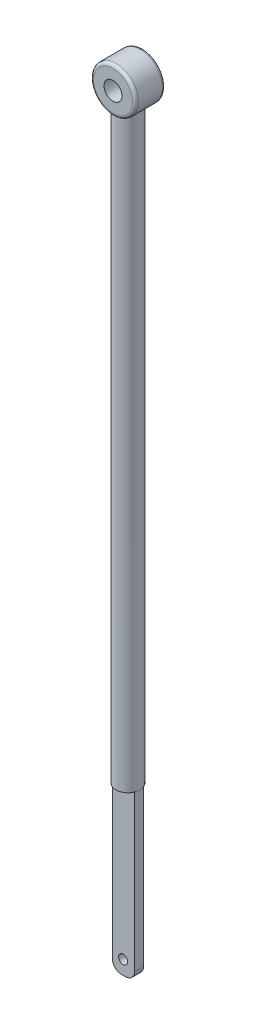
from build123d import *

# Parameters (mm, degrees)
SKETCH_1_R          = 0.75
SKETCH_1_R_2        = 0.3
EXTRUDE_1_DEPTH     = 1
FILLET_1_R          = 0.1
EXTRUDE_2_DEPTH     = 40
SKETCH_3_R          = 2.953544
CUT_EXTRUDE_1_DEPTH = 20
SKETCH_4_W          = 0.74162
SKETCH_4_H          = 0.3
EXTRUDE_3_DEPTH     = 5.5
SKETCH_6_R          = 0.15
CUT_EXTRUDE_2_DEPTH = 5.5
FILLET_2_R          = 0.3


with BuildPart() as part:
    # 草图1 → 凸台-拉伸1 (new body)
    with BuildSketch(Plane.XY):
        with Locations((0.75, 0)):
            Circle(SKETCH_1_R)
        with Locations((0.75, 0)):
            Circle(SKETCH_1_R_2, mode=Mode.SUBTRACT)
    extrude(amount=EXTRUDE_1_DEPTH)

    # 圆角1
    fillet_1_edges = [part.edges().sort_by_distance(p)[0] for p in [
        (0, 0, 1),
        (0, 0, 0),
    ]]
    fillet(fillet_1_edges, radius=FILLET_1_R)

    # 草图2 → 凸台-拉伸2 (add)
    with BuildSketch(Plane(origin=(0, -0.3, 0), x_dir=(-1, 0, 0), z_dir=(0, 1, 0))):
        with BuildLine():
            ThreePointArc((-0.35, 0.5), (-0.652986, 0.888057), (-1.102941, 0.688235))
            Line((-1.102941, 0.688235), (-0.397059, 0.311765))
            ThreePointArc((-0.397059, 0.311765), (-0.361943, 0.402986), (-0.35, 0.5))
        make_face()
        with BuildLine():
            Line((-0.397059, 0.311765), (-1.102941, 0.688235))
            ThreePointArc((-1.102941, 0.688235), (-0.938235, 0.147059), (-0.397059, 0.311765))
        make_face()
    extrude(amount=-EXTRUDE_2_DEPTH)

    # 草图3 → 切除-拉伸1 (cut)
    with BuildSketch(Plane.XZ.offset(40.3)):
        with Locations((0.75, 0.5)):
            Circle(SKETCH_3_R)
    extrude(amount=-CUT_EXTRUDE_1_DEPTH, mode=Mode.SUBTRACT)

    # 草图4 → 凸台-拉伸3 (add)
    with BuildSketch(Plane.XZ.offset(20.3)):
        with Locations((0.75, 0.5)):
            Rectangle(SKETCH_4_W, SKETCH_4_H)
    extrude(amount=EXTRUDE_3_DEPTH)

    # 草图6 → 切除-拉伸2 (cut)
    with BuildSketch(Plane(origin=(0, 0, 0.35), x_dir=(-1, 0, 0), z_dir=(0, 0, -1))):
        with Locations((-0.737636, -25.336312)):
            Circle(SKETCH_6_R)
    extrude(amount=-CUT_EXTRUDE_2_DEPTH, mode=Mode.SUBTRACT)

    # 圆角2
    fillet_2_edges = [part.edges().sort_by_distance(p)[0] for p in [
        (1.12081, -25.8, 0.5),
        (0.37919, -25.8, 0.5),
    ]]
    fillet(fillet_2_edges, radius=FILLET_2_R)


solid = part.part
